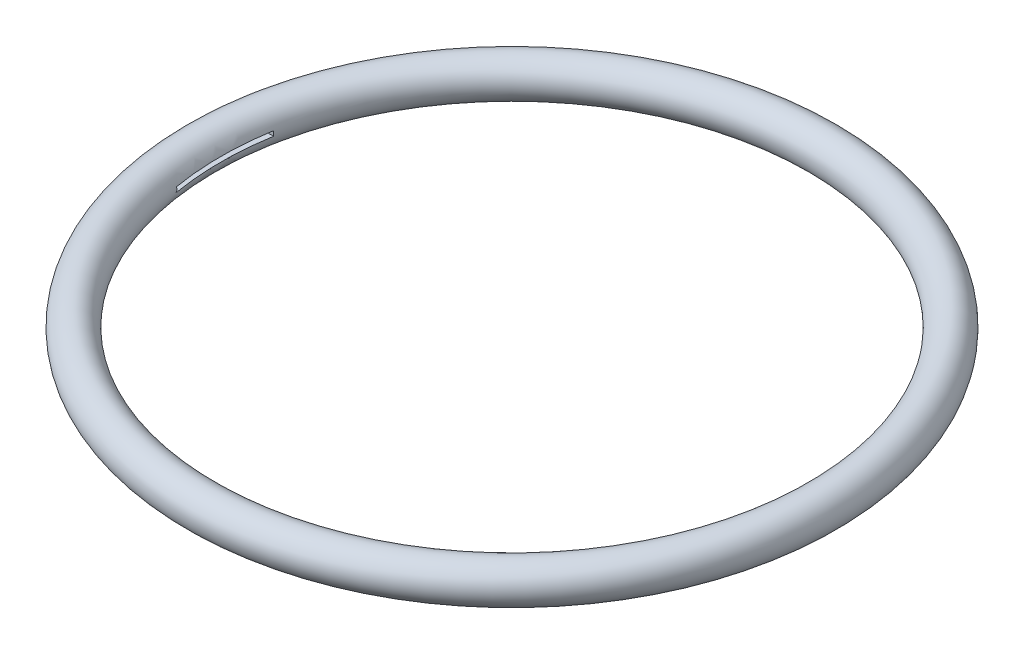
from build123d import *

# Parameters (mm, degrees)
SKETCH1_R          = 2
SKETCH1_R_2        = 1
SKETCH2_R          = 1
CUT_EXTRUDE1_DEPTH = 6
CUT_EXTRUDE2_REACH = 68
SKETCH3_W          = 10
SKETCH3_H          = 0.5


with BuildPart() as part:
    # Sketch1 → Revolve1 (revolve)
    with BuildSketch(Plane.XY):
        Circle(SKETCH1_R)
        Circle(SKETCH1_R_2, mode=Mode.SUBTRACT)
    revolve(axis=Axis((32, 4.090399727, 0), (0, -1, 0)))

    # Sketch2 → Cut-Extrude1 (cut, symmetric)
    with BuildSketch(Plane.XY):
        with Locations((0.5, 0)):
            Circle(SKETCH2_R)
    extrude(amount=CUT_EXTRUDE1_DEPTH, both=True, mode=Mode.SUBTRACT)

    # Sketch3 → Cut-Extrude2 (cut, up to next)
    with BuildSketch(Plane(origin=(0, 0, 0), x_dir=(0, 0, -1), z_dir=(1, 0, 0)), mode=Mode.PRIVATE) as cut_extrude2_sk1:
        Rectangle(SKETCH3_W, SKETCH3_H)
    cut_extrude2_tool1 = extrude(cut_extrude2_sk1.sketch, amount=CUT_EXTRUDE2_REACH, mode=Mode.PRIVATE) & part.part
    add(cut_extrude2_tool1.solids().sort_by_distance((0, 0, 0))[0], mode=Mode.SUBTRACT)


solid = part.part
